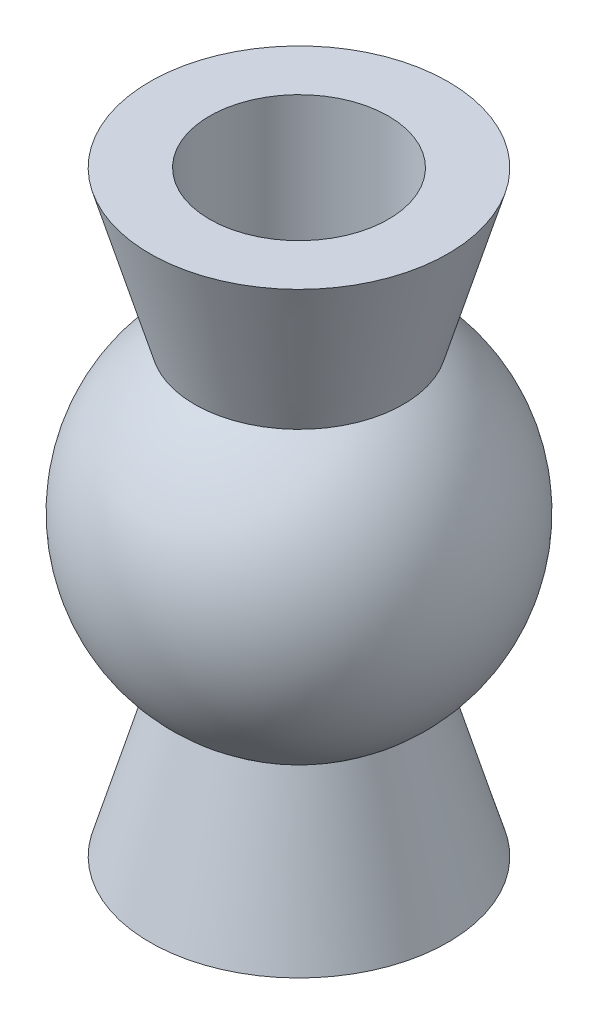
from build123d import *


with BuildPart() as part:
    # Sketch1 → Revolve1 (revolve)
    with BuildSketch(Plane.XY):
        with BuildLine():
            Line((2.5, 0), (1.5, 0))
            Line((1.5, 0), (1.5, 10))
            Line((1.5, 10), (2.5, 10))
            Line((2.5, 10), (1.75, 7.436698586))
            ThreePointArc((1.75, 7.436698586), (3, 5), (1.75, 2.563301414))
            Line((1.75, 2.563301414), (2.5, 0))
        make_face()
    revolve(axis=Axis((0, 0, 0), (0, 1, 0)))


solid = part.part
